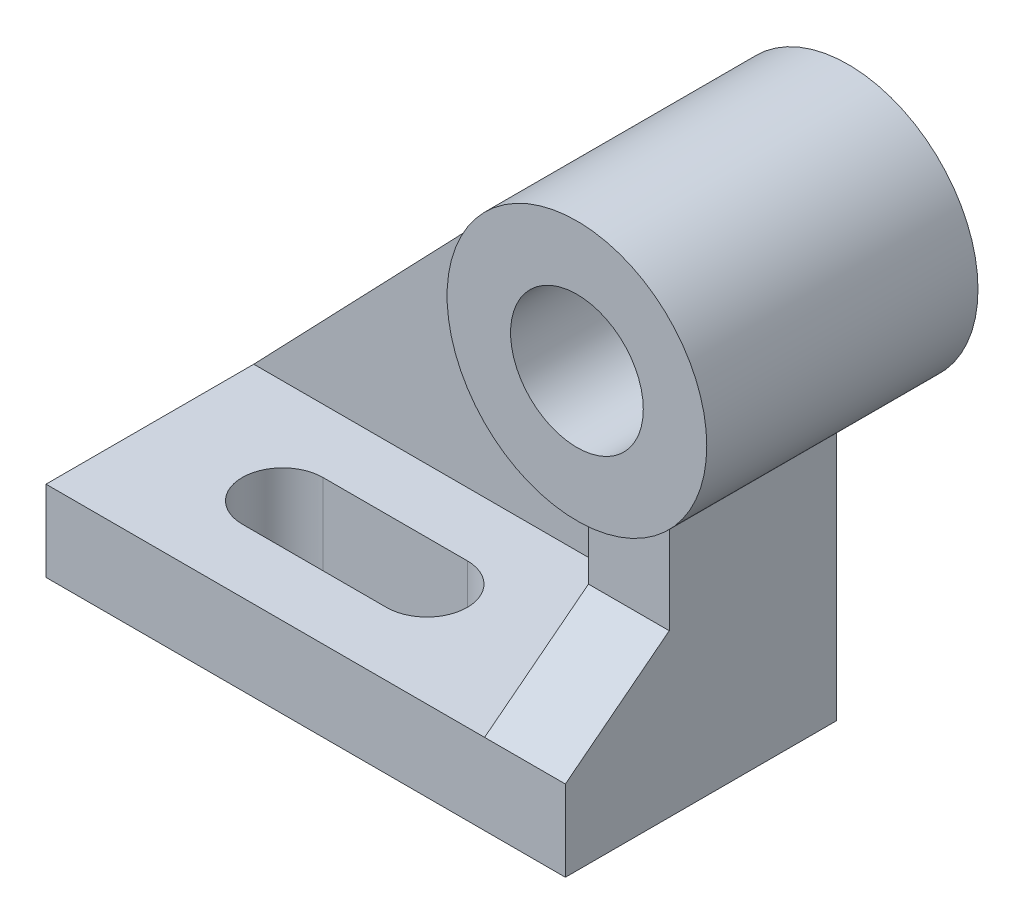
from build123d import *

# Parameters (mm, degrees)
SKETCH_1_R          = 22.5
SKETCH_1_R_2        = 11.5
EXTRUDE_1_DEPTH     = 47
EXTRUDE_2_DEPTH     = 47
EXTRUDE_3_DEPTH     = 11
EXTRUDE_10_DEPTH    = 29
EXTRUDE_11_DEPTH    = 14
CUT_EXTRUDE_1_DEPTH = 138


with BuildPart() as part:
    # 草图1 → 凸台-拉伸1 (new body)
    with BuildSketch(Plane.XY):
        Circle(SKETCH_1_R)
        Circle(SKETCH_1_R_2, mode=Mode.SUBTRACT)
    extrude(amount=EXTRUDE_1_DEPTH)



with BuildPart() as body_2:
    # 草图3 → 凸台-拉伸2 (new body)
    with BuildSketch(Plane.XY.offset(9)):
        Polygon((-83, -68), (0, -68), (7, -68), (7, -54), (-83, -54), align=None)
    extrude(amount=EXTRUDE_2_DEPTH)


with BuildPart() as part_1:
    add(part.part)

    add(body_2.part)  # 凸台-拉伸3 merges body 2
    # 草图4 → 凸台-拉伸3 (add)
    with BuildSketch(Plane.XY.offset(9)):
        with BuildLine():
            Line((-83, -54), (-16.234704276, 15.578330368))
            ThreePointArc((-16.234704276, 15.578330368), (-21.829002199, -5.453866793), (-7, -21.38340478))
            Line((-7, -21.38340478), (-7, -54))
            Line((-7, -54), (-83, -54))
        make_face()
    extrude(amount=EXTRUDE_3_DEPTH)

    # 草图6 → 凸台-拉伸10 (add)
    with BuildSketch(Plane.XY.offset(9)):
        with BuildLine():
            Line((-7, -21.38340478), (-7, -54))
            Line((-7, -54), (7, -54))
            Line((7, -54), (7, -21.38340478))
            ThreePointArc((7, -21.38340478), (0, -22.5), (-7, -21.38340478))
        make_face()
    extrude(amount=EXTRUDE_10_DEPTH)

    # 草图7 → 凸台-拉伸11 (add)
    with BuildSketch(Plane(origin=(7, 0, 0), x_dir=(0, 0, -1), z_dir=(1, 0, 0))):
        Polygon((-38, -54), (-38, -40), (-56, -54), align=None)
    extrude(amount=-EXTRUDE_11_DEPTH)

    # 草图8 → 切除-拉伸1 (cut)
    with BuildSketch(Plane(origin=(0, -168, 0), x_dir=(-1, 0, 0), z_dir=(0, -1, 0))):
        with BuildLine():
            Line((60, -45), (35, -45))
            ThreePointArc((35, -45), (28, -38), (35, -31))
            Line((35, -31), (60, -31))
            ThreePointArc((60, -31), (67, -38), (60, -45))
        make_face()
    extrude(amount=-CUT_EXTRUDE_1_DEPTH, mode=Mode.SUBTRACT)


solid = part_1.part
